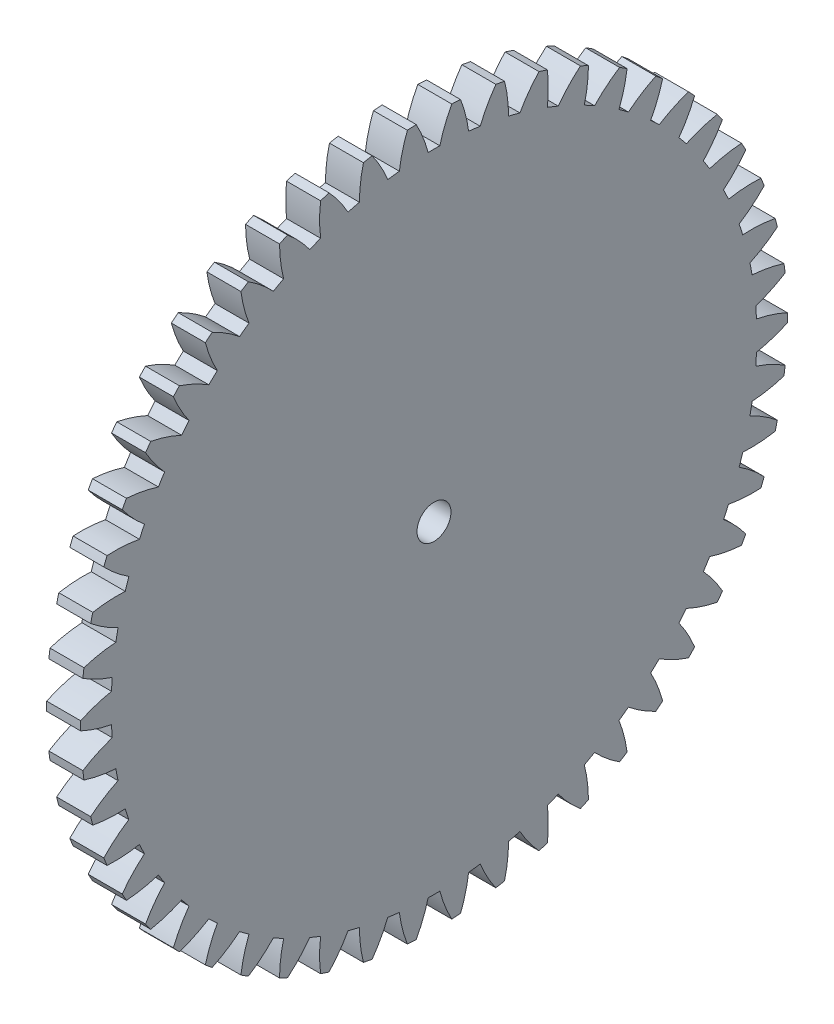
from build123d import *

# Parameters (mm, degrees)
BASPROSKE_W     = 5
BASPROSKE_H     = 52
TOOTHCUT_DEPTH  = 74.708886845
TEETHCUTS_COUNT = 50
TEETHCUTS_ANGLE = 352.8
BORSKE_R        = 2.5
BORE_DEPTH      = 50.0000508


with BuildPart() as part:
    # BasProSke → Base-Revolve (revolve)
    with BuildSketch(Plane(origin=(0, 0, 0), x_dir=(1, 0, 0), z_dir=(0, 1, 0)), mode=Mode.PRIVATE) as base_revolve_sk:
        with Locations((2.5, 26)):
            Rectangle(BASPROSKE_W, BASPROSKE_H)
    revolve(base_revolve_sk.sketch.rotate(Axis((-10, 0, 0), (1, 0, 0)), 180), axis=Axis((-10, 0, 0), (1, 0, 0)))

    # TooCutSke → ToothCut (cut, through all)
    with BuildSketch(Plane(origin=(0, 0, 0), x_dir=(0, 0, -1), z_dir=(1, 0, 0))):
        with BuildLine():
            ThreePointArc((0.86062222, 47.491202663), (0, 47.499), (-0.86062222, 47.491202663))
            ThreePointArc((-0.86062222, 47.491202663), (-1.610166517, 49.778366785), (-2.629027787, 51.958930494))
            ThreePointArc((-2.629027787, 51.958930494), (0, 52.0254), (2.629027787, 51.958930494))
            ThreePointArc((2.629027787, 51.958930494), (1.610166517, 49.778366785), (0.86062222, 47.491202663))
        make_face()
    toothcut = extrude(amount=TOOTHCUT_DEPTH, mode=Mode.SUBTRACT)

    # TeethCuts: ToothCut ×50 about axis
    teethcuts_axis = Axis((-10, 0, 0), (1, 0, 0))
    for i in range(1, TEETHCUTS_COUNT):
        add(toothcut.rotate(teethcuts_axis, i * TEETHCUTS_ANGLE / (TEETHCUTS_COUNT - 1)), mode=Mode.SUBTRACT)

    # BorSke → Bore (cut, symmetric)
    with BuildSketch(Plane(origin=(0, 0, 0), x_dir=(0, 0, -1), z_dir=(1, 0, 0))):
        with Locations(Location((0, 0, 0), (0, 0, 180))):
            Circle(BORSKE_R)
    extrude(amount=BORE_DEPTH, both=True, mode=Mode.SUBTRACT)


solid = part.part
